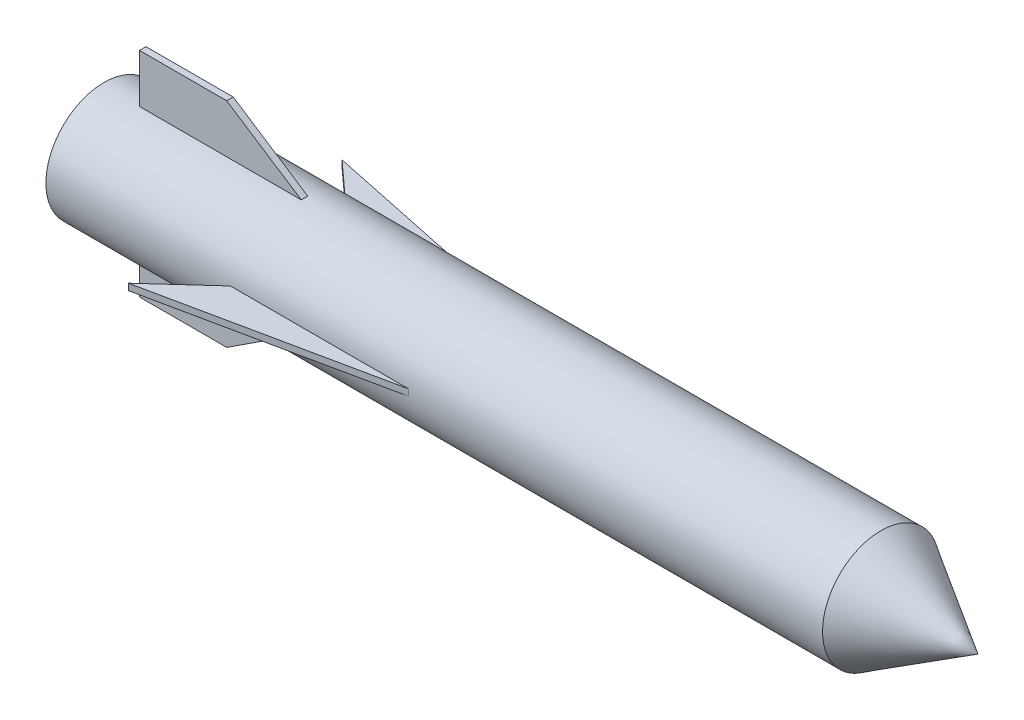
from build123d import *

# Parameters (mm, degrees)
BOSS_EXTRUDE1_DEPTH        = 30480
BOSS_EXTRUDE1_DEPTH_BACK   = 30480
SKETCH1_R                  = 4572
BOSS_EXTRUDE2_DEPTH        = 254
BOSS_EXTRUDE2_DEPTH_BACK   = 254
BOSS_EXTRUDE2_2_DEPTH      = 254
BOSS_EXTRUDE2_2_DEPTH_BACK = 254
BOSS_EXTRUDE3_DEPTH        = 254
BOSS_EXTRUDE3_DEPTH_BACK   = 254
BOSS_EXTRUDE3_2_DEPTH      = 254
BOSS_EXTRUDE3_2_DEPTH_BACK = 254


with BuildPart() as part:
    # Sketch1 → Boss-Extrude1 (new, two sides: drawn at the far end of the back side and taken through both)
    with BuildSketch(Plane(origin=(0, 0, 0), x_dir=(0, 0, -1), z_dir=(1, 0, 0)).offset(-BOSS_EXTRUDE1_DEPTH_BACK)):
        Circle(SKETCH1_R)
    extrude(amount=BOSS_EXTRUDE1_DEPTH + BOSS_EXTRUDE1_DEPTH_BACK)

    # Sketch3 → Revolve1 (revolve)
    with BuildSketch(Plane(origin=(0, 0, 0), x_dir=(1, 0, 0), z_dir=(0, 1, 0))):
        Polygon((30480, 0), (38100, 0), (30480, 4579.050119839), align=None)
    revolve(axis=Axis((30480, 0, 0), (1, 0, 0)))


with BuildPart() as body_2:
    # Sketch4 → Boss-Extrude2 (new, two sides: drawn at the far end of the back side and taken through both)
    with BuildSketch(Plane.XY.offset(-BOSS_EXTRUDE2_DEPTH_BACK)):
        Polygon((-27453.919833627, 4572), (-27453.919833627, 8382), (-20608.330564008, 8382), (-14753.919833627, 4572), align=None)
    extrude(amount=BOSS_EXTRUDE2_DEPTH + BOSS_EXTRUDE2_DEPTH_BACK)


with BuildPart() as body_3:
    # Sketch4 → Boss-Extrude2 2 (new, two sides: drawn at the far end of the back side and taken through both)
    with BuildSketch(Plane.XY.offset(-BOSS_EXTRUDE2_2_DEPTH_BACK)):
        Polygon((-27453.919833627, -4572), (-27453.919833627, -8382), (-20608.330564008, -8382), (-14753.919833627, -4572), align=None)
    extrude(amount=BOSS_EXTRUDE2_2_DEPTH + BOSS_EXTRUDE2_2_DEPTH_BACK)


with BuildPart() as body_4:
    # Sketch5 → Boss-Extrude3 (new, two sides: drawn at the far end of the back side and taken through both)
    with BuildSketch(Plane(origin=(0, 0, 0), x_dir=(1, 0, 0), z_dir=(0, 1, 0)).offset(-BOSS_EXTRUDE3_DEPTH_BACK)):
        Polygon((-2032, 4572), (-20193, 8382), (-16002, 4572), align=None)
    extrude(amount=BOSS_EXTRUDE3_DEPTH + BOSS_EXTRUDE3_DEPTH_BACK)


with BuildPart() as body_5:
    # Sketch5 → Boss-Extrude3 2 (new, two sides: drawn at the far end of the back side and taken through both)
    with BuildSketch(Plane(origin=(0, 0, 0), x_dir=(1, 0, 0), z_dir=(0, 1, 0)).offset(-BOSS_EXTRUDE3_2_DEPTH_BACK)):
        Polygon((-2032, -4572), (-20193, -8382), (-16002, -4572), align=None)
    extrude(amount=BOSS_EXTRUDE3_2_DEPTH + BOSS_EXTRUDE3_2_DEPTH_BACK)


solid = Compound([part.part, body_2.part, body_3.part, body_4.part, body_5.part])
